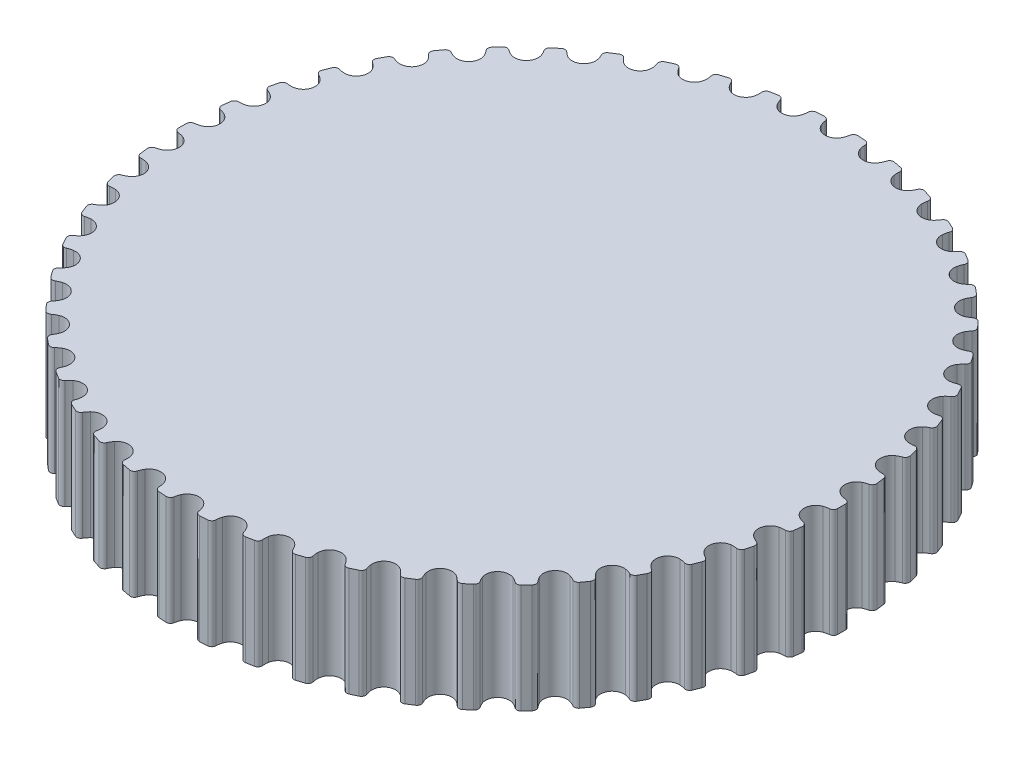
from build123d import *

# Parameters (mm, degrees)
BOSS_EXTRUDE1_DEPTH = 13


with BuildPart() as part:
    # Sketch2 → Boss-Extrude1 (new body)
    with BuildSketch(Plane(origin=(0, 0, 0), x_dir=(1, 0, 0), z_dir=(0, 1, 0))):
        with BuildLine():
            Line((-2.922437983, 39.164880178), (-2.009267388, 39.222332002))
            ThreePointArc((-2.009267388, 39.222332002), (-1.659878864, 39.11189905), (-1.475677281, 38.795138012))
            ThreePointArc((-1.475677281, 38.795138012), (-1.402326316, 38.468155381), (-1.288512298, 38.152965954))
            ThreePointArc((-1.288512298, 38.152965954), (0, 37.307535905), (1.288512298, 38.152965954))
            ThreePointArc((1.288512298, 38.152965954), (1.402326316, 38.468155381), (1.475677281, 38.795138012))
            ThreePointArc((1.475677281, 38.795138012), (1.659878864, 39.11189905), (2.009267388, 39.222332002))
            Line((2.009267388, 39.222332002), (2.922437983, 39.164880178))
            ThreePointArc((2.922437983, 39.164880178), (3.255230556, 39.011528029), (3.398278968, 38.674178167))
            ThreePointArc((3.398278968, 38.674178167), (3.430069749, 38.340580577), (3.503482599, 38.013611835))
            ThreePointArc((3.503482599, 38.013611835), (4.675874111, 37.013354841), (6.060186587, 37.690625009))
            ThreePointArc((6.060186587, 37.690625009), (6.212606857, 37.989064394), (6.326361219, 38.304275356))
            ThreePointArc((6.326361219, 38.304275356), (6.548811002, 38.595452058), (6.909285412, 38.66122422))
            Line((6.909285412, 38.66122422), (7.808054762, 38.489774797))
            ThreePointArc((7.808054762, 38.489774797), (8.119003045, 38.295921907), (8.218642329, 37.943303429))
            ThreePointArc((8.218642329, 37.943303429), (8.208371565, 37.608351915), (8.240225483, 37.274760349))
            ThreePointArc((8.240225483, 37.274760349), (9.278006895, 36.135451061), (10.736288113, 36.633880392))
            ThreePointArc((10.736288113, 36.633880392), (10.924910877, 36.910863168), (11.077274661, 37.209331396))
            ThreePointArc((11.077274661, 37.209331396), (11.334464478, 37.470331732), (11.700339878, 37.490405837))
            Line((11.700339878, 37.490405837), (12.570533852, 37.207662675))
            ThreePointArc((12.570533852, 37.207662675), (12.854734006, 36.976366219), (12.90939279, 36.61404013))
            ThreePointArc((12.90939279, 36.61404013), (12.857222458, 36.283017076), (12.847015089, 35.948063625))
            ThreePointArc((12.847015089, 35.948063625), (13.733819967, 34.687669631), (15.243071962, 34.999397598))
            ThreePointArc((15.243071962, 34.999397598), (15.464922526, 35.250555581), (15.653492864, 35.527574051))
            ThreePointArc((15.653492864, 35.527574051), (15.941366679, 35.754281891), (16.306872995, 35.728341359))
            Line((16.306872995, 35.728341359), (17.134768115, 35.338763487))
            ThreePointArc((17.134768115, 35.338763487), (17.387738132, 35.073671148), (17.396554415, 34.707351545))
            ThreePointArc((17.396554415, 34.707351545), (17.303307272, 34.385477384), (17.251199592, 34.054444463))
            ThreePointArc((17.251199592, 34.054444463), (17.973042494, 32.69284293), (19.509463461, 32.812953395))
            ThreePointArc((19.509463461, 32.812953395), (19.761043109, 33.034325674), (19.982846134, 33.285525641))
            ThreePointArc((19.982846134, 33.285525641), (20.296864005, 33.474365666), (20.656236983, 33.402819594))
            Line((20.656236983, 33.402819594), (21.428776848, 32.912550887))
            ThreePointArc((21.428776848, 32.912550887), (21.646527242, 32.61784333), (21.609361985, 32.253307294))
            ThreePointArc((21.609361985, 32.253307294), (21.476508594, 31.945658173), (21.383322372, 31.623766369))
            ThreePointArc((21.383322372, 31.623766369), (21.928819404, 30.182430566), (23.468179066, 30.109029316))
            ThreePointArc((23.468179066, 30.109029316), (23.745520237, 30.297124718), (23.997057983, 30.518544608))
            ThreePointArc((23.997057983, 30.518544608), (24.33226766, 30.666538697), (24.679839774, 30.55051541))
            Line((24.679839774, 30.55051541), (25.38484097, 29.967287699))
            ThreePointArc((25.38484097, 29.967287699), (25.563937685, 29.647612638), (25.481377008, 29.29060912))
            ThreePointArc((25.481377008, 29.29060912), (25.311012547, 29.002036849), (25.178217385, 28.694362589))
            ThreePointArc((25.178217385, 28.694362589), (25.538765733, 27.196023241), (27.056787468, 26.930267859))
            ThreePointArc((27.056787468, 26.930267859), (27.355516326, 27.082120006), (27.632821893, 27.270267895))
            ThreePointArc((27.632821893, 27.270267895), (27.983936919, 27.375082094), (28.31422675, 27.216411348))
            Line((28.31422675, 27.216411348), (28.940570985, 26.549422483))
            ThreePointArc((28.940570985, 26.549422483), (29.07818956, 26.209821385), (28.951535493, 25.865980542))
            ThreePointArc((28.951535493, 25.865980542), (28.746346711, 25.601036078), (28.576036869, 25.312431569))
            ThreePointArc((28.576036869, 25.312431569), (28.74595047, 23.780718384), (30.218694169, 23.32679999))
            ThreePointArc((30.218694169, 23.32679999), (30.534099581, 23.440014084), (30.832799694, 23.591922767))
            ThreePointArc((30.832799694, 23.591922767), (31.194282776, 23.651904093), (31.502081455, 23.453088221))
            Line((31.502081455, 23.453088221), (32.039890908, 22.712857014))
            ThreePointArc((32.039890908, 22.712857014), (32.133861016, 22.358685591), (31.965110969, 22.033429999))
            ThreePointArc((31.965110969, 22.033429999), (31.728333815, 21.796291676), (31.523195181, 21.531308382))
            ThreePointArc((31.523195181, 21.531308382), (31.499794396, 19.990377393), (32.904034011, 19.35545455))
            ThreePointArc((32.904034011, 19.35545455), (33.231141846, 19.428245137), (33.546525825, 19.541518924))
            ThreePointArc((33.546525825, 19.541518924), (33.912676159, 19.555721436), (34.193129517, 19.319895883))
            Line((34.193129517, 19.319895883), (34.633922611, 18.518096222))
            ThreePointArc((34.633922611, 18.518096222), (34.682762287, 18.154939969), (34.47457755, 17.853399104))
            ThreePointArc((34.47457755, 17.853399104), (34.209946142, 17.647806733), (33.973213874, 17.4106236))
            ThreePointArc((33.973213874, 17.4106236), (33.756867748, 15.884776208), (35.070457581, 15.07886203))
            ThreePointArc((35.070457581, 15.07886203), (35.404109152, 15.110081159), (35.731203205, 15.182933654))
            ThreePointArc((35.731203205, 15.182933654), (36.09624638, 15.15113337), (36.344931501, 14.882017245))
            Line((36.344931501, 14.882017245), (36.681756666, 14.03129399))
            ThreePointArc((36.681756666, 14.03129399), (36.684695679, 13.664880098), (36.440359449, 13.391809439))
            ThreePointArc((36.440359449, 13.391809439), (36.152047181, 13.221005336), (35.887454689, 13.015362883))
            ThreePointArc((35.887454689, 13.015362883), (35.48157513, 11.528662613), (36.683799084, 10.564466848))
            ThreePointArc((36.683799084, 10.564466848), (37.018732508, 10.553622174), (37.352378165, 10.58490445))
            ThreePointArc((37.352378165, 10.58490445), (37.710557234, 10.507602879), (37.923552204, 10.209440305))
            Line((37.923552204, 10.209440305), (38.151097505, 9.32320987))
            ThreePointArc((38.151097505, 9.32320987), (38.108089505, 8.959316905), (37.831455111, 8.71902294))
            ThreePointArc((37.831455111, 8.71902294), (37.524008841, 8.585700787), (37.235728906, 8.414842119))
            ThreePointArc((37.235728906, 8.414842119), (36.646716876, 6.990735122), (37.718615163, 5.883463713))
            ThreePointArc((37.718615163, 5.883463713), (38.049548338, 5.830726263), (38.384483808, 5.819944981))
            ThreePointArc((38.384483808, 5.819944981), (38.730150072, 5.698361215), (38.904095834, 5.375854393))
            Line((38.904095834, 5.375854393), (39.018772746, 4.468093161))
            ThreePointArc((39.018772746, 4.468093161), (38.930495995, 4.112459933), (38.625926126, 3.90873224))
            ThreePointArc((38.625926126, 3.90873224), (38.304194465, 3.814994607), (37.996773435, 3.681614268))
            ThreePointArc((37.996773435, 3.681614268), (37.233918005, 2.342559562), (38.158586148, 1.10967484))
            ThreePointArc((38.158586148, 1.10967484), (38.480300061, 1.015876316), (38.811243212, 0.963201502))
            ThreePointArc((38.811243212, 0.963201502), (39.138945308, 0.799252989), (39.271098632, 0.457488046))
            Line((39.271098632, 0.457488046), (39.271098632, -0.457488046))
            ThreePointArc((39.271098632, -0.457488046), (39.138945308, -0.799252989), (38.811243212, -0.963201502))
            ThreePointArc((38.811243212, -0.963201502), (38.480300061, -1.015876316), (38.158586148, -1.10967484))
            ThreePointArc((38.158586148, -1.10967484), (37.233918005, -2.342559562), (37.996773435, -3.681614268))
            ThreePointArc((37.996773435, -3.681614268), (38.304194465, -3.814994607), (38.625926126, -3.90873224))
            ThreePointArc((38.625926126, -3.90873224), (38.930495995, -4.112459933), (39.018772746, -4.468093161))
            Line((39.018772746, -4.468093161), (38.904095834, -5.375854393))
            ThreePointArc((38.904095834, -5.375854393), (38.730150072, -5.698361215), (38.384483808, -5.819944981))
            ThreePointArc((38.384483808, -5.819944981), (38.049548338, -5.830726263), (37.718615163, -5.883463713))
            ThreePointArc((37.718615163, -5.883463713), (36.646716876, -6.990735122), (37.235728906, -8.414842119))
            ThreePointArc((37.235728906, -8.414842119), (37.524008841, -8.585700787), (37.831455111, -8.71902294))
            ThreePointArc((37.831455111, -8.71902294), (38.108089505, -8.959316905), (38.151097505, -9.32320987))
            Line((38.151097505, -9.32320987), (37.923552204, -10.209440305))
            ThreePointArc((37.923552204, -10.209440305), (37.710557234, -10.507602879), (37.352378165, -10.58490445))
            ThreePointArc((37.352378165, -10.58490445), (37.018732508, -10.553622174), (36.683799084, -10.564466848))
            ThreePointArc((36.683799084, -10.564466848), (35.48157513, -11.528662613), (35.887454689, -13.015362883))
            ThreePointArc((35.887454689, -13.015362883), (36.152047181, -13.221005336), (36.440359449, -13.391809439))
            ThreePointArc((36.440359449, -13.391809439), (36.684695679, -13.664880098), (36.681756666, -14.03129399))
            Line((36.681756666, -14.03129399), (36.344931501, -14.882017245))
            ThreePointArc((36.344931501, -14.882017245), (36.09624638, -15.15113337), (35.731203205, -15.182933654))
            ThreePointArc((35.731203205, -15.182933654), (35.404109152, -15.110081159), (35.070457581, -15.07886203))
            ThreePointArc((35.070457581, -15.07886203), (33.756867748, -15.884776208), (33.973213874, -17.4106236))
            ThreePointArc((33.973213874, -17.4106236), (34.209946142, -17.647806733), (34.47457755, -17.853399104))
            ThreePointArc((34.47457755, -17.853399104), (34.682762287, -18.154939969), (34.633922611, -18.518096222))
            Line((34.633922611, -18.518096222), (34.193129517, -19.319895883))
            ThreePointArc((34.193129517, -19.319895883), (33.912676159, -19.555721436), (33.546525825, -19.541518924))
            ThreePointArc((33.546525825, -19.541518924), (33.231141846, -19.428245137), (32.904034011, -19.35545455))
            ThreePointArc((32.904034011, -19.35545455), (31.499794396, -19.990377393), (31.523195181, -21.531308382))
            ThreePointArc((31.523195181, -21.531308382), (31.728333815, -21.796291676), (31.965110969, -22.033429999))
            ThreePointArc((31.965110969, -22.033429999), (32.133861016, -22.358685591), (32.039890908, -22.712857014))
            Line((32.039890908, -22.712857014), (31.502081455, -23.453088221))
            ThreePointArc((31.502081455, -23.453088221), (31.194282776, -23.651904093), (30.832799694, -23.591922767))
            ThreePointArc((30.832799694, -23.591922767), (30.534099581, -23.440014084), (30.218694169, -23.32679999))
            ThreePointArc((30.218694169, -23.32679999), (28.74595047, -23.780718384), (28.576036869, -25.312431569))
            ThreePointArc((28.576036869, -25.312431569), (28.746346711, -25.601036078), (28.951535493, -25.865980542))
            ThreePointArc((28.951535493, -25.865980542), (29.07818956, -26.209821385), (28.940570985, -26.549422483))
            Line((28.940570985, -26.549422483), (28.31422675, -27.216411348))
            ThreePointArc((28.31422675, -27.216411348), (27.983936919, -27.375082094), (27.632821893, -27.270267895))
            ThreePointArc((27.632821893, -27.270267895), (27.355516326, -27.082120006), (27.056787468, -26.930267859))
            ThreePointArc((27.056787468, -26.930267859), (25.538765733, -27.196023241), (25.178217385, -28.694362589))
            ThreePointArc((25.178217385, -28.694362589), (25.311012547, -29.002036849), (25.481377008, -29.29060912))
            ThreePointArc((25.481377008, -29.29060912), (25.563937685, -29.647612638), (25.38484097, -29.967287699))
            Line((25.38484097, -29.967287699), (24.679839774, -30.55051541))
            ThreePointArc((24.679839774, -30.55051541), (24.33226766, -30.666538697), (23.997057983, -30.518544608))
            ThreePointArc((23.997057983, -30.518544608), (23.745520237, -30.297124718), (23.468179066, -30.109029316))
            ThreePointArc((23.468179066, -30.109029316), (21.928819404, -30.182430566), (21.383322372, -31.623766369))
            ThreePointArc((21.383322372, -31.623766369), (21.476508594, -31.945658173), (21.609361985, -32.253307294))
            ThreePointArc((21.609361985, -32.253307294), (21.646527242, -32.61784333), (21.428776848, -32.912550887))
            Line((21.428776848, -32.912550887), (20.656236983, -33.402819594))
            ThreePointArc((20.656236983, -33.402819594), (20.296864005, -33.474365666), (19.982846134, -33.285525641))
            ThreePointArc((19.982846134, -33.285525641), (19.761043109, -33.034325674), (19.509463461, -32.812953395))
            ThreePointArc((19.509463461, -32.812953395), (17.973042494, -32.69284293), (17.251199592, -34.054444463))
            ThreePointArc((17.251199592, -34.054444463), (17.303307272, -34.385477384), (17.396554415, -34.707351545))
            ThreePointArc((17.396554415, -34.707351545), (17.387738132, -35.073671148), (17.134768115, -35.338763487))
            Line((17.134768115, -35.338763487), (16.306872995, -35.728341359))
            ThreePointArc((16.306872995, -35.728341359), (15.941366679, -35.754281891), (15.653492864, -35.527574051))
            ThreePointArc((15.653492864, -35.527574051), (15.464922526, -35.250555581), (15.243071962, -34.999397598))
            ThreePointArc((15.243071962, -34.999397598), (13.733819967, -34.687669631), (12.847015089, -35.948063625))
            ThreePointArc((12.847015089, -35.948063625), (12.857222458, -36.283017076), (12.90939279, -36.61404013))
            ThreePointArc((12.90939279, -36.61404013), (12.854734006, -36.976366219), (12.570533852, -37.207662675))
            Line((12.570533852, -37.207662675), (11.700339878, -37.490405837))
            ThreePointArc((11.700339878, -37.490405837), (11.334464478, -37.470331732), (11.077274661, -37.209331396))
            ThreePointArc((11.077274661, -37.209331396), (10.924910877, -36.910863168), (10.736288113, -36.633880392))
            ThreePointArc((10.736288113, -36.633880392), (9.278006895, -36.135451061), (8.240225483, -37.274760349))
            ThreePointArc((8.240225483, -37.274760349), (8.208371565, -37.608351915), (8.218642329, -37.943303429))
            ThreePointArc((8.218642329, -37.943303429), (8.119003045, -38.295921907), (7.808054762, -38.489774797))
            Line((7.808054762, -38.489774797), (6.909285412, -38.66122422))
            ThreePointArc((6.909285412, -38.66122422), (6.548811002, -38.595452058), (6.326361219, -38.304275356))
            ThreePointArc((6.326361219, -38.304275356), (6.212606857, -37.989064394), (6.060186587, -37.690625009))
            ThreePointArc((6.060186587, -37.690625009), (4.675874111, -37.013354841), (3.503482599, -38.013611835))
            ThreePointArc((3.503482599, -38.013611835), (3.430069749, -38.340580577), (3.398278968, -38.674178167))
            ThreePointArc((3.398278968, -38.674178167), (3.255230556, -39.011528029), (2.922437983, -39.164880178))
            Line((2.922437983, -39.164880178), (2.009267388, -39.222332002))
            ThreePointArc((2.009267388, -39.222332002), (1.659878864, -39.11189905), (1.475677281, -38.795138012))
            ThreePointArc((1.475677281, -38.795138012), (1.402326316, -38.468155381), (1.288512298, -38.152965954))
            ThreePointArc((1.288512298, -38.152965954), (0, -37.307535905), (-1.288512298, -38.152965954))
            ThreePointArc((-1.288512298, -38.152965954), (-1.402326316, -38.468155381), (-1.475677281, -38.795138012))
            ThreePointArc((-1.475677281, -38.795138012), (-1.659878864, -39.11189905), (-2.009267388, -39.222332002))
            Line((-2.009267388, -39.222332002), (-2.922437983, -39.164880178))
            ThreePointArc((-2.922437983, -39.164880178), (-3.255230556, -39.011528029), (-3.398278968, -38.674178167))
            ThreePointArc((-3.398278968, -38.674178167), (-3.430069749, -38.340580577), (-3.503482599, -38.013611835))
            ThreePointArc((-3.503482599, -38.013611835), (-4.675874111, -37.013354841), (-6.060186587, -37.690625009))
            ThreePointArc((-6.060186587, -37.690625009), (-6.212606857, -37.989064394), (-6.326361219, -38.304275356))
            ThreePointArc((-6.326361219, -38.304275356), (-6.548811002, -38.595452058), (-6.909285412, -38.66122422))
            Line((-6.909285412, -38.66122422), (-7.808054762, -38.489774797))
            ThreePointArc((-7.808054762, -38.489774797), (-8.119003045, -38.295921907), (-8.218642329, -37.943303429))
            ThreePointArc((-8.218642329, -37.943303429), (-8.208371565, -37.608351915), (-8.240225483, -37.274760349))
            ThreePointArc((-8.240225483, -37.274760349), (-9.278006895, -36.135451061), (-10.736288113, -36.633880392))
            ThreePointArc((-10.736288113, -36.633880392), (-10.924910877, -36.910863168), (-11.077274661, -37.209331396))
            ThreePointArc((-11.077274661, -37.209331396), (-11.334464478, -37.470331732), (-11.700339878, -37.490405837))
            Line((-11.700339878, -37.490405837), (-12.570533852, -37.207662675))
            ThreePointArc((-12.570533852, -37.207662675), (-12.854734006, -36.976366219), (-12.90939279, -36.61404013))
            ThreePointArc((-12.90939279, -36.61404013), (-12.857222458, -36.283017076), (-12.847015089, -35.948063625))
            ThreePointArc((-12.847015089, -35.948063625), (-13.733819967, -34.687669631), (-15.243071962, -34.999397598))
            ThreePointArc((-15.243071962, -34.999397598), (-15.464922526, -35.250555581), (-15.653492864, -35.527574051))
            ThreePointArc((-15.653492864, -35.527574051), (-15.941366679, -35.754281891), (-16.306872995, -35.728341359))
            Line((-16.306872995, -35.728341359), (-17.134768115, -35.338763487))
            ThreePointArc((-17.134768115, -35.338763487), (-17.387738132, -35.073671148), (-17.396554415, -34.707351545))
            ThreePointArc((-17.396554415, -34.707351545), (-17.303307272, -34.385477384), (-17.251199592, -34.054444463))
            ThreePointArc((-17.251199592, -34.054444463), (-17.973042494, -32.69284293), (-19.509463461, -32.812953395))
            ThreePointArc((-19.509463461, -32.812953395), (-19.761043109, -33.034325674), (-19.982846134, -33.285525641))
            ThreePointArc((-19.982846134, -33.285525641), (-20.296864005, -33.474365666), (-20.656236983, -33.402819594))
            Line((-20.656236983, -33.402819594), (-21.428776848, -32.912550887))
            ThreePointArc((-21.428776848, -32.912550887), (-21.646527242, -32.61784333), (-21.609361985, -32.253307294))
            ThreePointArc((-21.609361985, -32.253307294), (-21.476508594, -31.945658173), (-21.383322372, -31.623766369))
            ThreePointArc((-21.383322372, -31.623766369), (-21.928819404, -30.182430566), (-23.468179066, -30.109029316))
            ThreePointArc((-23.468179066, -30.109029316), (-23.745520237, -30.297124718), (-23.997057983, -30.518544608))
            ThreePointArc((-23.997057983, -30.518544608), (-24.33226766, -30.666538697), (-24.679839774, -30.55051541))
            Line((-24.679839774, -30.55051541), (-25.38484097, -29.967287699))
            ThreePointArc((-25.38484097, -29.967287699), (-25.563937685, -29.647612638), (-25.481377008, -29.29060912))
            ThreePointArc((-25.481377008, -29.29060912), (-25.311012547, -29.002036849), (-25.178217385, -28.694362589))
            ThreePointArc((-25.178217385, -28.694362589), (-25.538765733, -27.196023241), (-27.056787468, -26.930267859))
            ThreePointArc((-27.056787468, -26.930267859), (-27.355516326, -27.082120006), (-27.632821893, -27.270267895))
            ThreePointArc((-27.632821893, -27.270267895), (-27.983936919, -27.375082094), (-28.31422675, -27.216411348))
            Line((-28.31422675, -27.216411348), (-28.940570985, -26.549422483))
            ThreePointArc((-28.940570985, -26.549422483), (-29.07818956, -26.209821385), (-28.951535493, -25.865980542))
            ThreePointArc((-28.951535493, -25.865980542), (-28.746346711, -25.601036078), (-28.576036869, -25.312431569))
            ThreePointArc((-28.576036869, -25.312431569), (-28.74595047, -23.780718384), (-30.218694169, -23.32679999))
            ThreePointArc((-30.218694169, -23.32679999), (-30.534099581, -23.440014084), (-30.832799694, -23.591922767))
            ThreePointArc((-30.832799694, -23.591922767), (-31.194282776, -23.651904093), (-31.502081455, -23.453088221))
            Line((-31.502081455, -23.453088221), (-32.039890908, -22.712857014))
            ThreePointArc((-32.039890908, -22.712857014), (-32.133861016, -22.358685591), (-31.965110969, -22.033429999))
            ThreePointArc((-31.965110969, -22.033429999), (-31.728333815, -21.796291676), (-31.523195181, -21.531308382))
            ThreePointArc((-31.523195181, -21.531308382), (-31.499794396, -19.990377393), (-32.904034011, -19.35545455))
            ThreePointArc((-32.904034011, -19.35545455), (-33.231141846, -19.428245137), (-33.546525825, -19.541518924))
            ThreePointArc((-33.546525825, -19.541518924), (-33.912676159, -19.555721436), (-34.193129517, -19.319895883))
            Line((-34.193129517, -19.319895883), (-34.633922611, -18.518096222))
            ThreePointArc((-34.633922611, -18.518096222), (-34.682762287, -18.154939969), (-34.47457755, -17.853399104))
            ThreePointArc((-34.47457755, -17.853399104), (-34.209946142, -17.647806733), (-33.973213874, -17.4106236))
            ThreePointArc((-33.973213874, -17.4106236), (-33.756867748, -15.884776208), (-35.070457581, -15.07886203))
            ThreePointArc((-35.070457581, -15.07886203), (-35.404109152, -15.110081159), (-35.731203205, -15.182933654))
            ThreePointArc((-35.731203205, -15.182933654), (-36.09624638, -15.15113337), (-36.344931501, -14.882017245))
            Line((-36.344931501, -14.882017245), (-36.681756666, -14.03129399))
            ThreePointArc((-36.681756666, -14.03129399), (-36.684695679, -13.664880098), (-36.440359449, -13.391809439))
            ThreePointArc((-36.440359449, -13.391809439), (-36.152047181, -13.221005336), (-35.887454689, -13.015362883))
            ThreePointArc((-35.887454689, -13.015362883), (-35.48157513, -11.528662613), (-36.683799084, -10.564466848))
            ThreePointArc((-36.683799084, -10.564466848), (-37.018732508, -10.553622174), (-37.352378165, -10.58490445))
            ThreePointArc((-37.352378165, -10.58490445), (-37.710557234, -10.507602879), (-37.923552204, -10.209440305))
            Line((-37.923552204, -10.209440305), (-38.151097505, -9.32320987))
            ThreePointArc((-38.151097505, -9.32320987), (-38.108089505, -8.959316905), (-37.831455111, -8.71902294))
            ThreePointArc((-37.831455111, -8.71902294), (-37.524008841, -8.585700787), (-37.235728906, -8.414842119))
            ThreePointArc((-37.235728906, -8.414842119), (-36.646716876, -6.990735122), (-37.718615163, -5.883463713))
            ThreePointArc((-37.718615163, -5.883463713), (-38.049548338, -5.830726263), (-38.384483808, -5.819944981))
            ThreePointArc((-38.384483808, -5.819944981), (-38.730150072, -5.698361215), (-38.904095834, -5.375854393))
            Line((-38.904095834, -5.375854393), (-39.018772746, -4.468093161))
            ThreePointArc((-39.018772746, -4.468093161), (-38.930495995, -4.112459933), (-38.625926126, -3.90873224))
            ThreePointArc((-38.625926126, -3.90873224), (-38.304194465, -3.814994607), (-37.996773435, -3.681614268))
            ThreePointArc((-37.996773435, -3.681614268), (-37.233918005, -2.342559562), (-38.158586148, -1.10967484))
            ThreePointArc((-38.158586148, -1.10967484), (-38.480300061, -1.015876316), (-38.811243212, -0.963201502))
            ThreePointArc((-38.811243212, -0.963201502), (-39.138945308, -0.799252989), (-39.271098632, -0.457488046))
            Line((-39.271098632, -0.457488046), (-39.271098632, 0.457488046))
            ThreePointArc((-39.271098632, 0.457488046), (-39.138945308, 0.799252989), (-38.811243212, 0.963201502))
            ThreePointArc((-38.811243212, 0.963201502), (-38.480300061, 1.015876316), (-38.158586148, 1.10967484))
            ThreePointArc((-38.158586148, 1.10967484), (-37.233918005, 2.342559562), (-37.996773435, 3.681614268))
            ThreePointArc((-37.996773435, 3.681614268), (-38.304194465, 3.814994607), (-38.625926126, 3.90873224))
            ThreePointArc((-38.625926126, 3.90873224), (-38.930495995, 4.112459933), (-39.018772746, 4.468093161))
            Line((-39.018772746, 4.468093161), (-38.904095834, 5.375854393))
            ThreePointArc((-38.904095834, 5.375854393), (-38.730150072, 5.698361215), (-38.384483808, 5.819944981))
            ThreePointArc((-38.384483808, 5.819944981), (-38.049548338, 5.830726263), (-37.718615163, 5.883463713))
            ThreePointArc((-37.718615163, 5.883463713), (-36.646716876, 6.990735122), (-37.235728906, 8.414842119))
            ThreePointArc((-37.235728906, 8.414842119), (-37.524008841, 8.585700787), (-37.831455111, 8.71902294))
            ThreePointArc((-37.831455111, 8.71902294), (-38.108089505, 8.959316905), (-38.151097505, 9.32320987))
            Line((-38.151097505, 9.32320987), (-37.923552204, 10.209440305))
            ThreePointArc((-37.923552204, 10.209440305), (-37.710557234, 10.507602879), (-37.352378165, 10.58490445))
            ThreePointArc((-37.352378165, 10.58490445), (-37.018732508, 10.553622174), (-36.683799084, 10.564466848))
            ThreePointArc((-36.683799084, 10.564466848), (-35.48157513, 11.528662613), (-35.887454689, 13.015362883))
            ThreePointArc((-35.887454689, 13.015362883), (-36.152047181, 13.221005336), (-36.440359449, 13.391809439))
            ThreePointArc((-36.440359449, 13.391809439), (-36.684695679, 13.664880098), (-36.681756666, 14.03129399))
            Line((-36.681756666, 14.03129399), (-36.344931501, 14.882017245))
            ThreePointArc((-36.344931501, 14.882017245), (-36.09624638, 15.15113337), (-35.731203205, 15.182933654))
            ThreePointArc((-35.731203205, 15.182933654), (-35.404109152, 15.110081159), (-35.070457581, 15.07886203))
            ThreePointArc((-35.070457581, 15.07886203), (-33.756867748, 15.884776208), (-33.973213874, 17.4106236))
            ThreePointArc((-33.973213874, 17.4106236), (-34.209946142, 17.647806733), (-34.47457755, 17.853399104))
            ThreePointArc((-34.47457755, 17.853399104), (-34.682762287, 18.154939969), (-34.633922611, 18.518096222))
            Line((-34.633922611, 18.518096222), (-34.193129517, 19.319895883))
            ThreePointArc((-34.193129517, 19.319895883), (-33.912676159, 19.555721436), (-33.546525825, 19.541518924))
            ThreePointArc((-33.546525825, 19.541518924), (-33.231141846, 19.428245137), (-32.904034011, 19.35545455))
            ThreePointArc((-32.904034011, 19.35545455), (-31.499794396, 19.990377393), (-31.523195181, 21.531308382))
            ThreePointArc((-31.523195181, 21.531308382), (-31.728333815, 21.796291676), (-31.965110969, 22.033429999))
            ThreePointArc((-31.965110969, 22.033429999), (-32.133861016, 22.358685591), (-32.039890908, 22.712857014))
            Line((-32.039890908, 22.712857014), (-31.502081455, 23.453088221))
            ThreePointArc((-31.502081455, 23.453088221), (-31.194282776, 23.651904093), (-30.832799694, 23.591922767))
            ThreePointArc((-30.832799694, 23.591922767), (-30.534099581, 23.440014084), (-30.218694169, 23.32679999))
            ThreePointArc((-30.218694169, 23.32679999), (-28.74595047, 23.780718384), (-28.576036869, 25.312431569))
            ThreePointArc((-28.576036869, 25.312431569), (-28.746346711, 25.601036078), (-28.951535493, 25.865980542))
            ThreePointArc((-28.951535493, 25.865980542), (-29.07818956, 26.209821385), (-28.940570985, 26.549422483))
            Line((-28.940570985, 26.549422483), (-28.31422675, 27.216411348))
            ThreePointArc((-28.31422675, 27.216411348), (-27.983936919, 27.375082094), (-27.632821893, 27.270267895))
            ThreePointArc((-27.632821893, 27.270267895), (-27.355516326, 27.082120006), (-27.056787468, 26.930267859))
            ThreePointArc((-27.056787468, 26.930267859), (-25.538765733, 27.196023241), (-25.178217385, 28.694362589))
            ThreePointArc((-25.178217385, 28.694362589), (-25.311012547, 29.002036849), (-25.481377008, 29.29060912))
            ThreePointArc((-25.481377008, 29.29060912), (-25.563937685, 29.647612638), (-25.38484097, 29.967287699))
            Line((-25.38484097, 29.967287699), (-24.679839774, 30.55051541))
            ThreePointArc((-24.679839774, 30.55051541), (-24.33226766, 30.666538697), (-23.997057983, 30.518544608))
            ThreePointArc((-23.997057983, 30.518544608), (-23.745520237, 30.297124718), (-23.468179066, 30.109029316))
            ThreePointArc((-23.468179066, 30.109029316), (-21.928819404, 30.182430566), (-21.383322372, 31.623766369))
            ThreePointArc((-21.383322372, 31.623766369), (-21.476508594, 31.945658173), (-21.609361985, 32.253307294))
            ThreePointArc((-21.609361985, 32.253307294), (-21.646527242, 32.61784333), (-21.428776848, 32.912550887))
            Line((-21.428776848, 32.912550887), (-20.656236983, 33.402819594))
            ThreePointArc((-20.656236983, 33.402819594), (-20.296864005, 33.474365666), (-19.982846134, 33.285525641))
            ThreePointArc((-19.982846134, 33.285525641), (-19.761043109, 33.034325674), (-19.509463461, 32.812953395))
            ThreePointArc((-19.509463461, 32.812953395), (-17.973042494, 32.69284293), (-17.251199592, 34.054444463))
            ThreePointArc((-17.251199592, 34.054444463), (-17.303307272, 34.385477384), (-17.396554415, 34.707351545))
            ThreePointArc((-17.396554415, 34.707351545), (-17.387738132, 35.073671148), (-17.134768115, 35.338763487))
            Line((-17.134768115, 35.338763487), (-16.306872995, 35.728341359))
            ThreePointArc((-16.306872995, 35.728341359), (-15.941366679, 35.754281891), (-15.653492864, 35.527574051))
            ThreePointArc((-15.653492864, 35.527574051), (-15.464922526, 35.250555581), (-15.243071962, 34.999397598))
            ThreePointArc((-15.243071962, 34.999397598), (-13.733819967, 34.687669631), (-12.847015089, 35.948063625))
            ThreePointArc((-12.847015089, 35.948063625), (-12.857222458, 36.283017076), (-12.90939279, 36.61404013))
            ThreePointArc((-12.90939279, 36.61404013), (-12.854734006, 36.976366219), (-12.570533852, 37.207662675))
            Line((-12.570533852, 37.207662675), (-11.700339878, 37.490405837))
            ThreePointArc((-11.700339878, 37.490405837), (-11.334464478, 37.470331732), (-11.077274661, 37.209331396))
            ThreePointArc((-11.077274661, 37.209331396), (-10.924910877, 36.910863168), (-10.736288113, 36.633880392))
            ThreePointArc((-10.736288113, 36.633880392), (-9.278006895, 36.135451061), (-8.240225483, 37.274760349))
            ThreePointArc((-8.240225483, 37.274760349), (-8.208371565, 37.608351915), (-8.218642329, 37.943303429))
            ThreePointArc((-8.218642329, 37.943303429), (-8.119003045, 38.295921907), (-7.808054762, 38.489774797))
            Line((-7.808054762, 38.489774797), (-6.909285412, 38.66122422))
            ThreePointArc((-6.909285412, 38.66122422), (-6.548811002, 38.595452058), (-6.326361219, 38.304275356))
            ThreePointArc((-6.326361219, 38.304275356), (-6.212606857, 37.989064394), (-6.060186587, 37.690625009))
            ThreePointArc((-6.060186587, 37.690625009), (-4.675874111, 37.013354841), (-3.503482599, 38.013611835))
            ThreePointArc((-3.503482599, 38.013611835), (-3.430069749, 38.340580577), (-3.398278968, 38.674178167))
            ThreePointArc((-3.398278968, 38.674178167), (-3.255230556, 39.011528029), (-2.922437983, 39.164880178))
        make_face()
    extrude(amount=BOSS_EXTRUDE1_DEPTH)


solid = part.part
